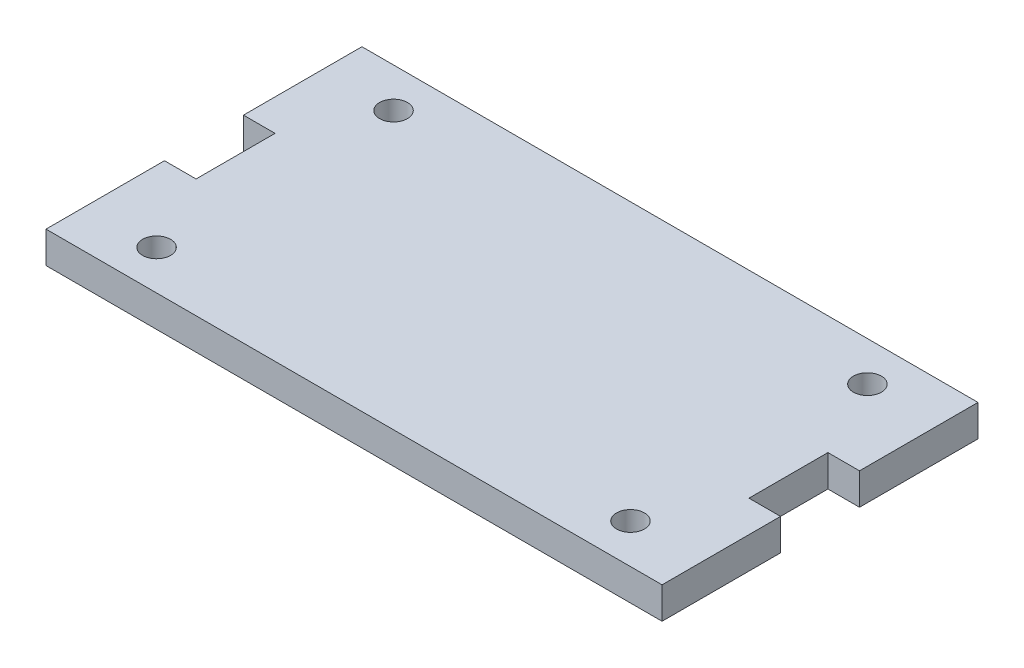
from build123d import *

# Parameters (mm, degrees)
SKETCH1_W             = 88.9
SKETCH1_H             = 50.8
SKETCH1_W_2           = 5.08
SKETCH1_H_2           = 19.05
BOSS_EXTRUDE1_DEPTH   = 5.08
F_8_CLEARANCE_HOLE1_D = 4.4958


with BuildPart() as part:
    # Sketch1 → Boss-Extrude1 (new body)
    with BuildSketch(Plane(origin=(0, 0, 0), x_dir=(1, 0, 0), z_dir=(0, 1, 0))):
        Rectangle(SKETCH1_W, SKETCH1_H)
        with Locations((-46.99, 15.875)):
            Rectangle(SKETCH1_W_2, SKETCH1_H_2)
        with Locations((-46.99, -15.875)):
            Rectangle(SKETCH1_W_2, SKETCH1_H_2)
        with Locations((46.99, -15.875)):
            Rectangle(SKETCH1_W_2, SKETCH1_H_2)
        with Locations((46.99, 15.875)):
            Rectangle(SKETCH1_W_2, SKETCH1_H_2)
    extrude(amount=BOSS_EXTRUDE1_DEPTH)

    # #8 Clearance Hole1 (through all)
    with Locations(Plane(origin=(0, 5.08, 0), x_dir=(1, 0, 0), z_dir=(0, 1, 0))):
        with Locations((-38.1, 19.05), (38.1, -19.05), (38.1, 19.05), (-38.1, -19.05)):
            Hole(F_8_CLEARANCE_HOLE1_D / 2)


solid = part.part
